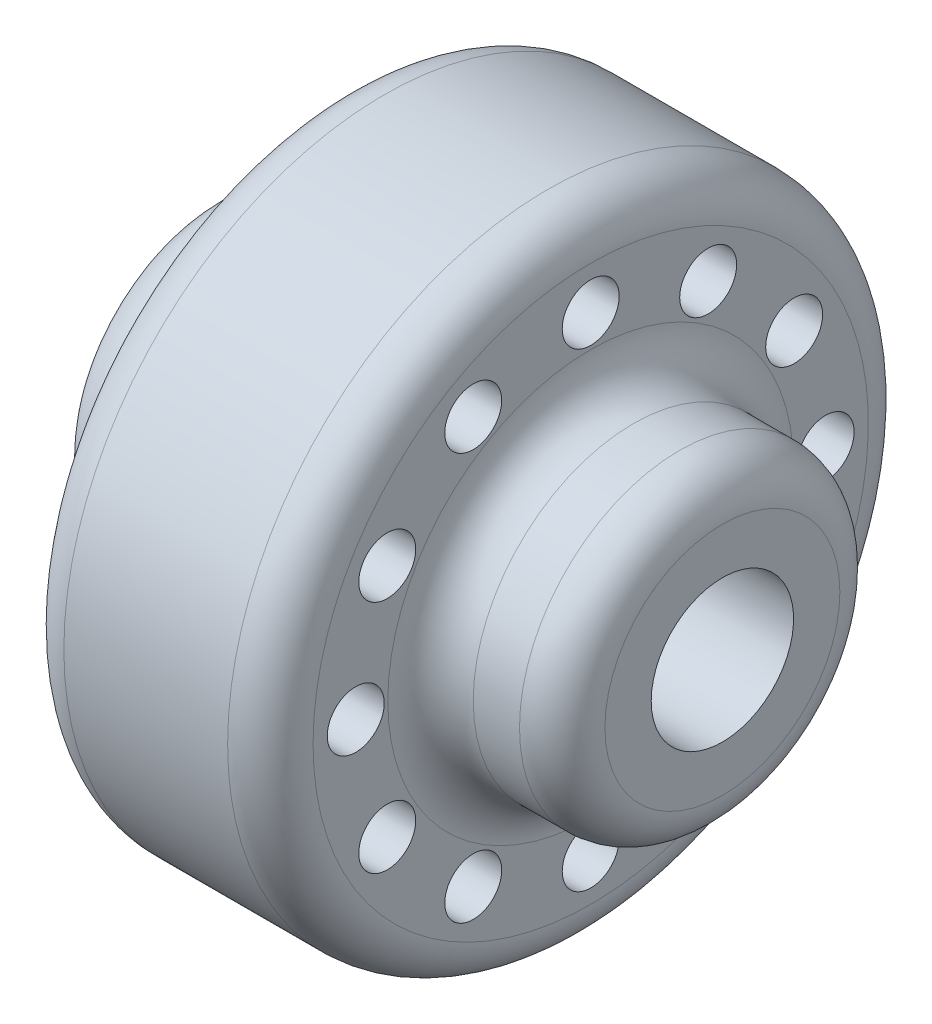
from build123d import *

# Parameters (mm, degrees)
SKETCH2_R          = 5
CUT_EXTRUDE1_DEPTH = 37
SKETCH3_R          = 2
CUT_EXTRUDE2_DEPTH = 27.75
CIRPATTERN1_COUNT  = 12


with BuildPart() as part:
    # Sketch1 → Revolve1 (revolve)
    with BuildSketch(Plane.XY):
        with BuildLine():
            Line((14.5, 22.5), (3, 22.5))
            ThreePointArc((3, 22.5), (0.878679656, 21.621320344), (0, 19.5))
            Line((0, 19.5), (0, 14.25))
            ThreePointArc((0, 14.25), (-0.878679656, 12.128679656), (-3, 11.25))
            Line((-3, 11.25), (-6.25, 11.25))
            ThreePointArc((-6.25, 11.25), (-8.371320344, 10.371320344), (-9.25, 8.25))
            Line((-9.25, 8.25), (-9.25, 0))
            Line((-9.25, 0), (26.75, 0))
            Line((26.75, 0), (26.75, 8.25))
            ThreePointArc((26.75, 8.25), (25.871320344, 10.371320344), (23.75, 11.25))
            Line((23.75, 11.25), (20.5, 11.25))
            ThreePointArc((20.5, 11.25), (18.378679656, 12.128679656), (17.5, 14.25))
            Line((17.5, 14.25), (17.5, 19.5))
            ThreePointArc((17.5, 19.5), (16.621320344, 21.621320344), (14.5, 22.5))
        make_face()
    revolve(axis=Axis((25, 0, 0), (1, 0, 0)))

    # Sketch2 → Cut-Extrude1 (cut, through all)
    with BuildSketch(Plane.ZY.offset(9.25)):
        Circle(SKETCH2_R)
    extrude(amount=-CUT_EXTRUDE1_DEPTH, mode=Mode.SUBTRACT)

    # Sketch3 → Cut-Extrude2 (cut, through all)
    with BuildSketch(Plane.ZY):
        with Locations((0, 16.5)):
            Circle(SKETCH3_R)
    cut_extrude2 = extrude(amount=-CUT_EXTRUDE2_DEPTH, mode=Mode.SUBTRACT)

    # CirPattern1: Cut-Extrude2 ×12 about axis
    cirpattern1_axis = Axis((0, 0, 0), (1, 0, 0))
    for i in range(1, CIRPATTERN1_COUNT):
        add(cut_extrude2.rotate(cirpattern1_axis, i * 360 / CIRPATTERN1_COUNT), mode=Mode.SUBTRACT)


solid = part.part
